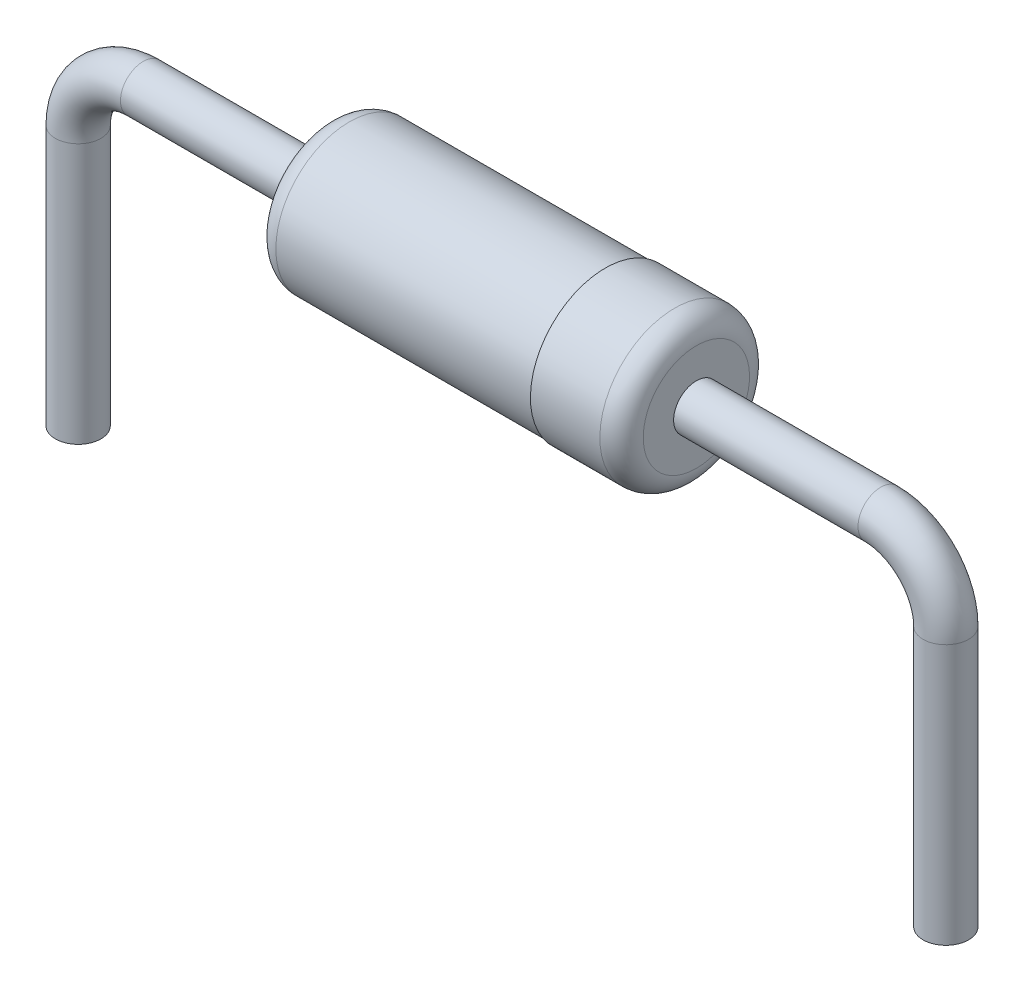
from build123d import *

# Parameters (mm, degrees)
SKETCH3_R           = 0.2665
SKETCH4_R           = 0.86
BOSS_EXTRUDE1_DEPTH = 2.159
SKETCH5_R           = 0.8763
BOSS_EXTRUDE2_DEPTH = 1.0668
FILLET2_R           = 0.254


with BuildPart() as part:
    # Base-Sweep: sweep along a path in Sketch2
    with BuildLine(Plane.XY) as base_sweep_path:
        Line((0, -2.54), (0, 0.508))
        ThreePointArc((0, 0.508), (0.223184633, 1.046815367), (0.762, 1.27))
        Line((0.762, 1.27), (2.921, 1.27))
    # Sketch3 → Base-Sweep (sweep)
    with BuildSketch(Plane(origin=(0, -2.54, 0), x_dir=(-1, 0, 0), z_dir=(0, 1, 0))):
        Circle(SKETCH3_R)
    sweep(path=base_sweep_path.line)

    # Sketch4 → Boss-Extrude1 (add)
    with BuildSketch(Plane(origin=(2.921, 0, 0), x_dir=(0, 0, -1), z_dir=(1, 0, 0))):
        with Locations(Location((0, 1.27, 0), (0, 0, 90))):  # turned: the seam where the file's is
            Circle(SKETCH4_R)
    extrude(amount=BOSS_EXTRUDE1_DEPTH)

    # Boss-Mirror1: part across plane


with BuildPart() as part_1:
    add(part.part)
    add(part.part.mirror(Plane(origin=(5.08, 1.27, 0), x_dir=(0, 0, 1), z_dir=(1, 0, 0))))

    # Sketch5 → Boss-Extrude2 (add)
    with BuildSketch(Plane.ZY.offset(-7.239)):
        with Locations(Location((0, 1.27, 0), (0, 0, 270))):  # turned: the seam where the file's is
            Circle(SKETCH5_R)
    extrude(amount=BOSS_EXTRUDE2_DEPTH)

    # Fillet2
    fillet2_edges = [part_1.edges().sort_by_distance(p)[0] for p in [
        (7.239, 2.1463, 0),
        (2.921, 0.41, 0),
    ]]
    fillet(fillet2_edges, radius=FILLET2_R)


solid = part_1.part
